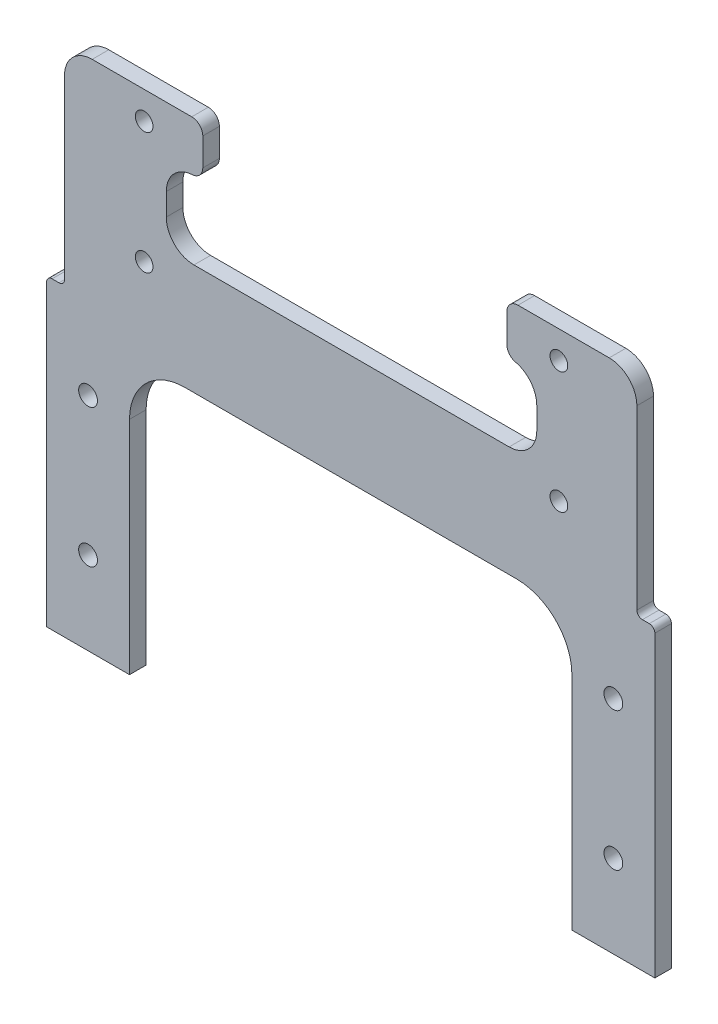
from build123d import *

# Parameters (mm, degrees)
SKETCH_1_W          = 110
SKETCH_1_H          = 55
SKETCH_1_R          = 1.7
EXTRUDE_1_DEPTH     = 3
SKETCH_2_W          = 103.5
SKETCH_2_H          = 38
EXTRUDE_2_DEPTH     = 3
SKETCH_3_R          = 1.6
CUT_EXTRUDE_1_DEPTH = 4
SKETCH_4_W          = 80
SKETCH_4_H          = 50
SKETCH_4_W_2        = 66.999999997
SKETCH_4_H_2        = 13.999999819
CUT_EXTRUDE_2_DEPTH = 4
FILLET_2_R          = 10
FILLET_3_R          = 1
FILLET_5_R          = 5
SKETCH_10_R         = 1.65
CUT_EXTRUDE_5_DEPTH = 4
SKETCH_11_W         = 55
SKETCH_11_H         = 9
CUT_EXTRUDE_6_DEPTH = 4
FILLET_6_R          = 2


with BuildPart() as part:
    # 草图1 → 凸台-拉伸1 (new body)
    with BuildSketch(Plane.XY):
        Rectangle(SKETCH_1_W, SKETCH_1_H)
        with Locations((-47.5, 12.5)):
            Circle(SKETCH_1_R, mode=Mode.SUBTRACT)
        with Locations((-47.5, -12.5)):
            Circle(SKETCH_1_R, mode=Mode.SUBTRACT)
        with Locations((47.5, 12.5)):
            Circle(SKETCH_1_R, mode=Mode.SUBTRACT)
        with Locations((47.5, -12.5)):
            Circle(SKETCH_1_R, mode=Mode.SUBTRACT)
    extrude(amount=EXTRUDE_1_DEPTH)

    # 草图2 → 凸台-拉伸2 (add)
    with BuildSketch(Plane.XY.offset(3)):
        with Locations((0, 46.5)):
            Rectangle(SKETCH_2_W, SKETCH_2_H)
    extrude(amount=-EXTRUDE_2_DEPTH)

    # 草图3 → 切除-拉伸1 (cut, through all)
    with BuildSketch(Plane(origin=(0, 0, 0), x_dir=(-1, 0, 0), z_dir=(0, 0, -1))):
        with Locations((37.35, 60.5)):
            Circle(SKETCH_3_R)
        with Locations((-37.649999997, 60.5)):
            Circle(SKETCH_3_R)
        with Locations((-37.649999997, 38.500000181)):
            Circle(SKETCH_3_R)
        with Locations((37.35, 38.500000181)):
            Circle(SKETCH_3_R)
    extrude(amount=-CUT_EXTRUDE_1_DEPTH, mode=Mode.SUBTRACT)

    # 草图4 → 切除-拉伸2 (cut, through all)
    with BuildSketch(Plane.XY.offset(3)):
        with Locations((0, -2.5)):
            Rectangle(SKETCH_4_W, SKETCH_4_H)
        with Locations((0.149999999, 49.500000091)):
            Rectangle(SKETCH_4_W_2, SKETCH_4_H_2)
    extrude(amount=-CUT_EXTRUDE_2_DEPTH, mode=Mode.SUBTRACT)

    # 圆角2
    fillet_2_edges = [part.edges().sort_by_distance(p)[0] for p in [
        (-40, 22.5, 1.5),
        (40, 22.5, 1.5),
    ]]
    fillet(fillet_2_edges, radius=FILLET_2_R)

    # 圆角3
    fillet_3_edges = [part.edges().sort_by_distance(p)[0] for p in [
        (51.75, 27.5, 1.5),
        (-51.75, 27.5, 1.5),
        (-55, 27.5, 1.5),
        (55, 27.5, 1.5),
    ]]
    fillet(fillet_3_edges, radius=FILLET_3_R)

    # 圆角5
    fillet_5_edges = [part.edges().sort_by_distance(p)[0] for p in [
        (-51.75, 65.5, 1.5),
        (51.75, 65.5, 1.5),
        (-33.35, 56.5, 1.5),
        (33.649999997, 56.5, 1.5),
        (33.649999997, 42.500000181, 1.5),
        (-33.35, 42.500000181, 1.5),
    ]]
    fillet(fillet_5_edges, radius=FILLET_5_R)

    # 草图10 → 切除-拉伸5 (cut, through all)
    with BuildSketch(Plane.XY.offset(3)):
        with Locations((-22.85, 60.5)):
            Circle(SKETCH_10_R)
        with Locations((5.15, 60.5)):
            Circle(SKETCH_10_R)
    extrude(amount=-CUT_EXTRUDE_5_DEPTH, mode=Mode.SUBTRACT)

    # 草图11 → 切除-拉伸6 (cut, through all)
    with BuildSketch(Plane.XY.offset(3)):
        with Locations((0.75, 61)):
            Rectangle(SKETCH_11_W, SKETCH_11_H)
    extrude(amount=-CUT_EXTRUDE_6_DEPTH, mode=Mode.SUBTRACT)

    # 圆角6
    fillet_6_edges = [part.edges().sort_by_distance(p)[0] for p in [
        (28.25, 56.5, 1.5),
        (28.25, 65.5, 1.5),
        (-26.75, 56.5, 1.5),
        (-26.75, 65.5, 1.5),
    ]]
    fillet(fillet_6_edges, radius=FILLET_6_R)


solid = part.part
